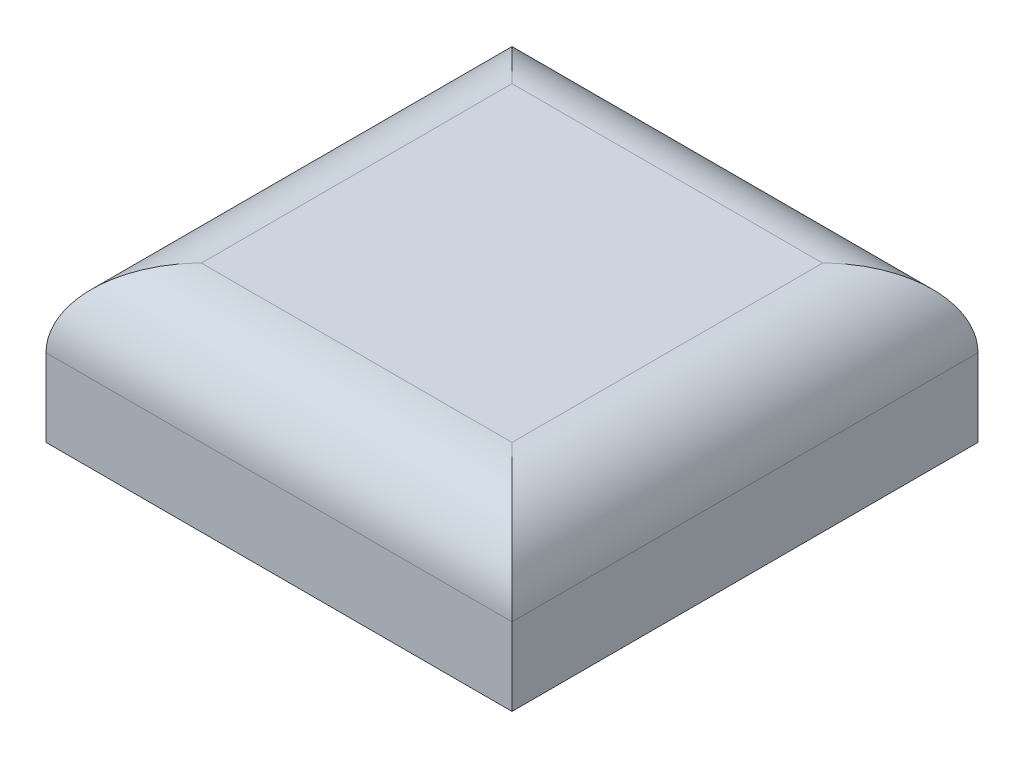
from build123d import *

# Parameters (mm, degrees)
SKETCH1_W           = 12
SKETCH1_H           = 12
BOSS_EXTRUDE1_DEPTH = 4
SKETCH2_R           = 2
CUT_EXTRUDE1_DEPTH  = 2
FILLET1_R           = 2


with BuildPart() as part:
    # Sketch1 → Boss-Extrude1 (new body)
    with BuildSketch(Plane(origin=(0, 0, 0), x_dir=(1, 0, 0), z_dir=(0, 1, 0))):
        with Locations((-9.023076923, 2.330769231)):
            Rectangle(SKETCH1_W, SKETCH1_H)
    extrude(amount=BOSS_EXTRUDE1_DEPTH)

    # Sketch2 → Cut-Extrude1 (cut)
    with BuildSketch(Plane.XZ):
        with Locations((-9.023076923, -2.330769231)):
            Circle(SKETCH2_R)
    extrude(amount=-CUT_EXTRUDE1_DEPTH, mode=Mode.SUBTRACT)

    # Fillet1
    fillet1_edges = [part.edges().sort_by_distance(p)[0] for p in [
        (-15.023076923, 4, -2.330769231),
        (-9.023076923, 4, 3.669230769),
        (-3.023076923, 4, -2.330769231),
        (-9.023076923, 4, -8.330769231),
    ]]
    fillet(fillet1_edges, radius=FILLET1_R)


solid = part.part
